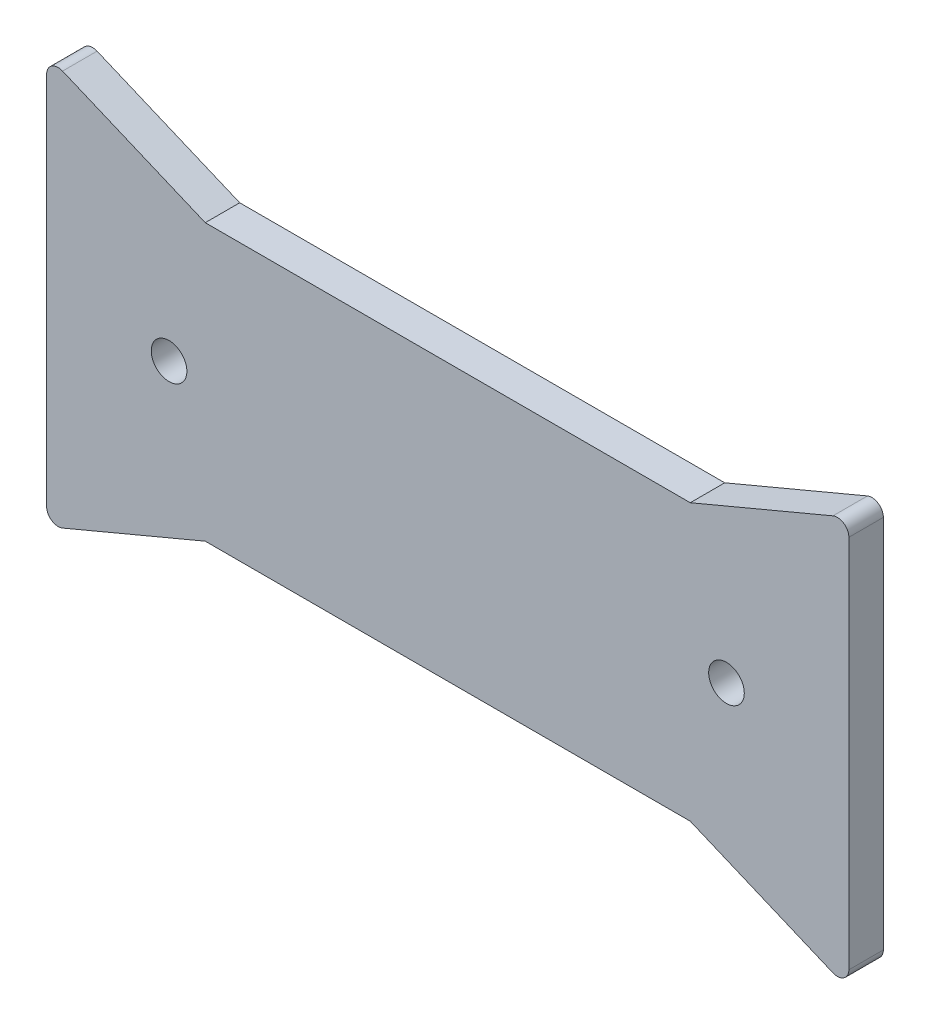
from build123d import *

# Parameters (mm, degrees)
EXTRUDE_1_DEPTH     = 3
FILLET_1_R          = 1
SKETCH_2_R          = 1.55
CUT_EXTRUDE_1_DEPTH = 4


with BuildPart() as part:
    # Эскиз1 → Бобышка-Вытянуть1 (new body)
    with BuildSketch(Plane.XY):
        Polygon((34.9, -12), (34.9, 12), (34.9, 17.8), (21.1, 12), (-21.1, 12), (-34.9, 17.8), (-34.9, 12), (-34.9, -12), (-34.9, -17.8), (-21.1, -12), (21.1, -12), (34.9, -17.8), align=None)
    extrude(amount=EXTRUDE_1_DEPTH)

    # Скругление1
    fillet_1_edges = [part.edges().sort_by_distance(p)[0] for p in [
        (-34.9, 17.8, 1.5),
        (34.9, 17.8, 1.5),
        (34.9, -17.8, 1.5),
        (-34.9, -17.8, 1.5),
    ]]
    fillet(fillet_1_edges, radius=FILLET_1_R)

    # Эскиз2 → Вырез-Вытянуть1 (cut, through all)
    with BuildSketch(Plane.XY.offset(3)):
        with Locations((-24.25, 0)):
            Circle(SKETCH_2_R)
        with Locations((24.25, 0)):
            Circle(SKETCH_2_R)
    extrude(amount=-CUT_EXTRUDE_1_DEPTH, mode=Mode.SUBTRACT)


solid = part.part
